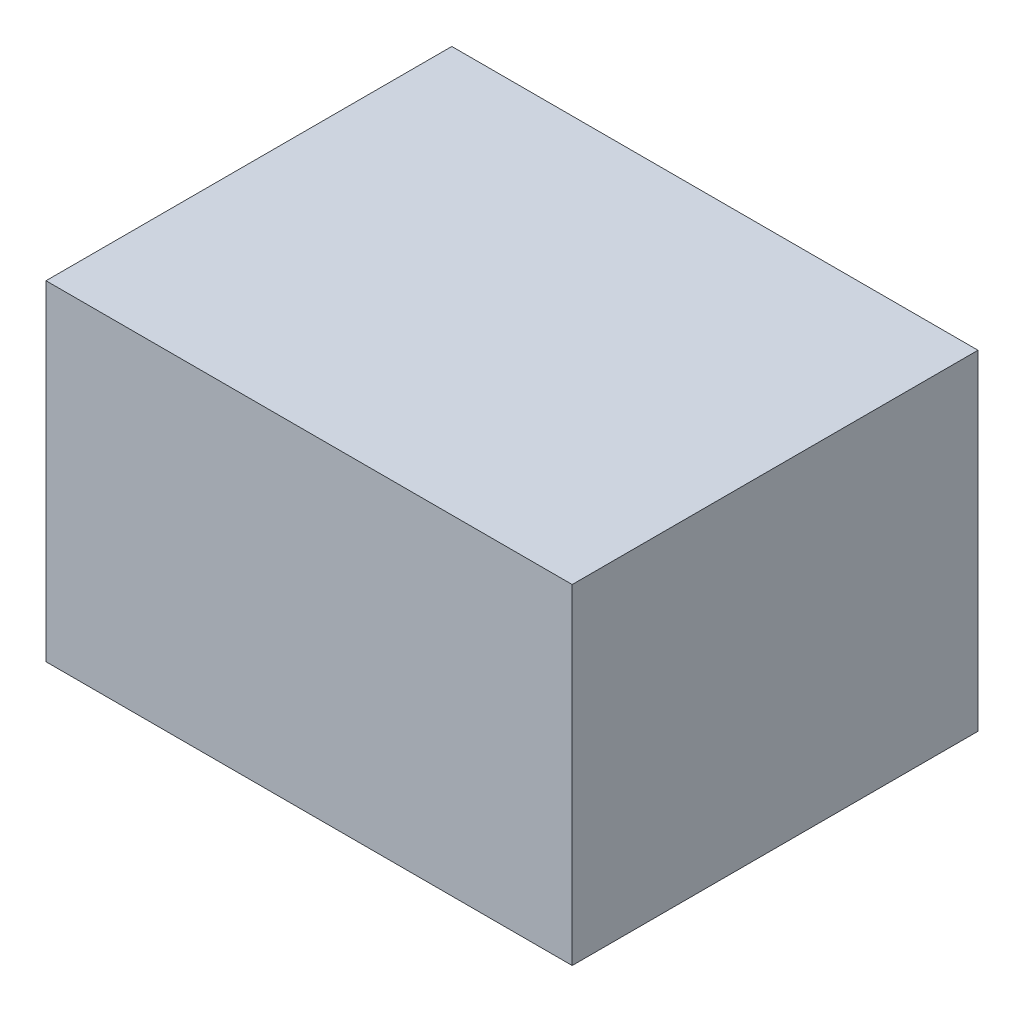
from build123d import *

# Parameters (mm, degrees)
BUTTONBASE_SKETCH_W      = 5.9
BUTTONBASE_SKETCH_H      = 4.55
BUTTONBASE_EXTRUDE_DEPTH = 3.7


with BuildPart() as part:
    # ButtonBase Sketch → ButtonBase Extrude (new body)
    with BuildSketch(Plane(origin=(0, 0, 0), x_dir=(1, 0, 0), z_dir=(0, 1, 0))):
        with Locations((2.95, 2.275)):
            Rectangle(BUTTONBASE_SKETCH_W, BUTTONBASE_SKETCH_H)
    extrude(amount=BUTTONBASE_EXTRUDE_DEPTH)


solid = part.part
